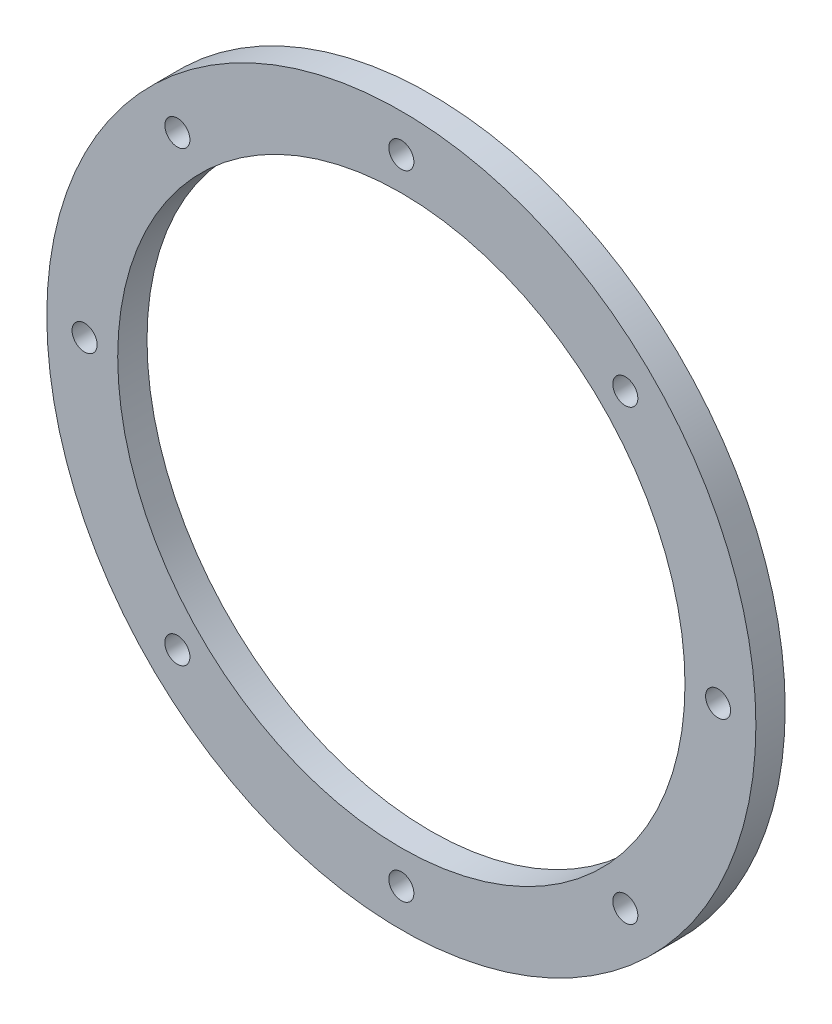
from build123d import *

# Parameters (mm, degrees)
SKETCH1_R           = 95.25
SKETCH1_R_2         = 76.2
BOSS_EXTRUDE1_DEPTH = 7.874
SKETCH2_R           = 3.3655
CUT_EXTRUDE1_DEPTH  = 8.874
CIRPATTERN1_COUNT   = 8


with BuildPart() as part:
    # Sketch1 → Boss-Extrude1 (new body)
    with BuildSketch(Plane.XY):
        Circle(SKETCH1_R)
        Circle(SKETCH1_R_2, mode=Mode.SUBTRACT)
    extrude(amount=BOSS_EXTRUDE1_DEPTH)

    # Sketch2 → Cut-Extrude1 (cut, through all)
    with BuildSketch(Plane.XY.offset(7.874)):
        with Locations((0, 85.09)):
            Circle(SKETCH2_R)
    cut_extrude1 = extrude(amount=-CUT_EXTRUDE1_DEPTH, mode=Mode.SUBTRACT)

    # CirPattern1: Cut-Extrude1 ×8 about axis
    cirpattern1_axis = Axis((0, 0, 0), (0, 0, 1))
    for i in range(1, CIRPATTERN1_COUNT):
        add(cut_extrude1.rotate(cirpattern1_axis, i * 360 / CIRPATTERN1_COUNT), mode=Mode.SUBTRACT)


solid = part.part
